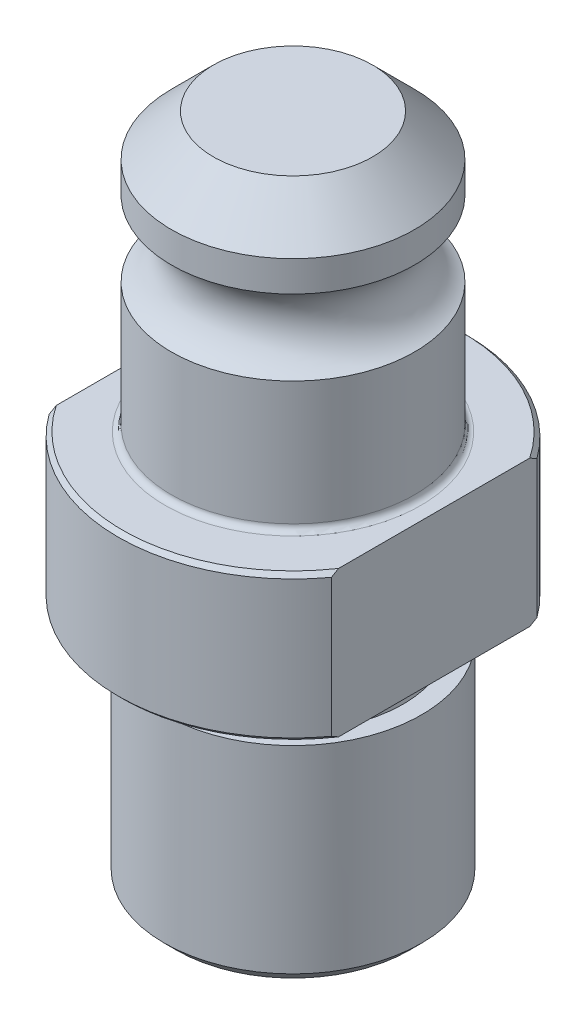
from build123d import *

# Parameters (mm, degrees)
CHAMFER1_SIZE      = 0.508
CHAMFER2_SIZE      = 1.524
CUT_EXTRUDE1_DEPTH = 49.26
FILLET1_R          = 0.762


with BuildPart() as part:
    # Sketch1 → Revolve1 (revolve)
    with BuildSketch(Plane.XY):
        with BuildLine():
            Line((0, 52.2986), (0, -30.2514))
            Line((0, -30.2514), (-15.875, -30.2514))
            Line((-15.875, -30.2514), (-15.875, -4.318))
            Line((-15.875, -4.318), (-13.6017, -4.318))
            Line((-13.6017, -4.318), (-13.6017, -1.27))
            ThreePointArc((-13.6017, -1.27), (-13.973674388, -0.371974388), (-14.8717, 0))
            Line((-14.8717, 0), (-21.5519, 0))
            Line((-21.5519, 0), (-21.5519, 18.0086))
            Line((-21.5519, 18.0086), (-15.0114, 18.0086))
            Line((-15.0114, 18.0086), (-15.0114, 34.036))
            ThreePointArc((-15.0114, 34.036), (-11.938, 38.6842), (-15.0114, 43.3324))
            Line((-15.0114, 43.3324), (-15.0114, 47.117))
            Line((-15.0114, 47.117), (-9.8298, 52.2986))
            Line((-9.8298, 52.2986), (0, 52.2986))
        make_face()
    revolve(axis=Axis((0, -30.2514, 0), (0, -1, 0)))

    # Chamfer1
    chamfer1_edges = [part.edges().sort_by_distance(p)[0] for p in [
        (21.5519, 18.0086, 0),
        (21.5519, 0, 0),
    ]]
    chamfer(chamfer1_edges, length=CHAMFER1_SIZE)

    # Chamfer2
    chamfer2_edges = [part.edges().sort_by_distance(p)[0] for p in [
        (15.875, -30.2514, 0),
    ]]
    chamfer(chamfer2_edges, length=CHAMFER2_SIZE)

    # Sketch2 → Cut-Extrude1 (cut, through all)
    with BuildSketch(Plane(origin=(0, 18.0086, 0), x_dir=(1, 0, 0), z_dir=(0, 1, 0))):
        with BuildLine():
            Line((-17.4244, 12.68363821), (-17.4244, -12.68363821))
            ThreePointArc((-17.4244, -12.68363821), (-21.5519, 0), (-17.4244, 12.68363821))
        make_face()
        with BuildLine():
            Line((17.4244, 12.68363821), (17.4244, -12.68363821))
            ThreePointArc((17.4244, -12.68363821), (21.5519, 0), (17.4244, 12.68363821))
        make_face()
    extrude(amount=-CUT_EXTRUDE1_DEPTH, mode=Mode.SUBTRACT)

    # Fillet1
    fillet1_edges = [part.edges().sort_by_distance(p)[0] for p in [
        (15.0114, 18.0086, 0),
    ]]
    fillet(fillet1_edges, radius=FILLET1_R)


solid = part.part
